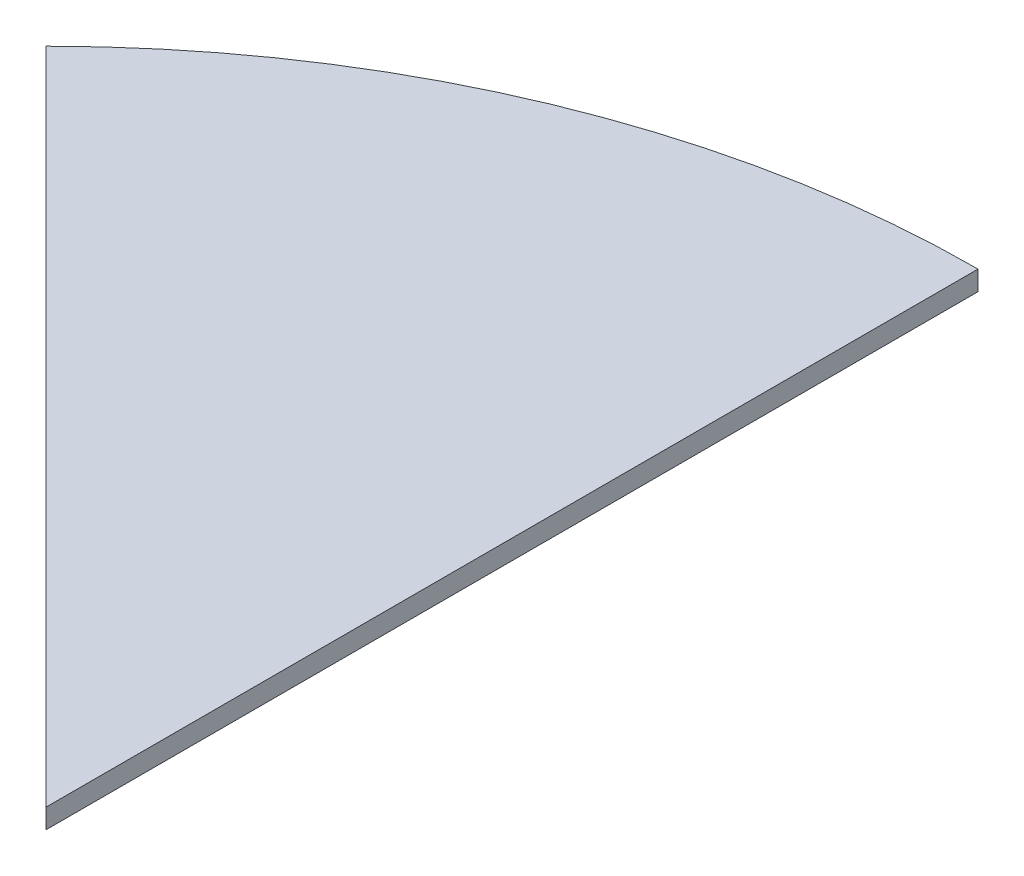
from build123d import *

# Parameters (mm, degrees)
EXTRUDE1_DEPTH = 20


with BuildPart() as part:
    # Sketch1 → Extrude1 (new body)
    with BuildSketch(Plane(origin=(0, 0, 0), x_dir=(1, 0, 0), z_dir=(0, 1, 0))):
        with BuildLine():
            Line((0, 950), (0, 0))
            Line((0, 0), (-671.751442127, 671.751442127))
            ThreePointArc((-671.751442127, 671.751442127), (-363.549260747, 877.685555886), (0, 950))
        make_face()
    extrude(amount=EXTRUDE1_DEPTH)


solid = part.part
